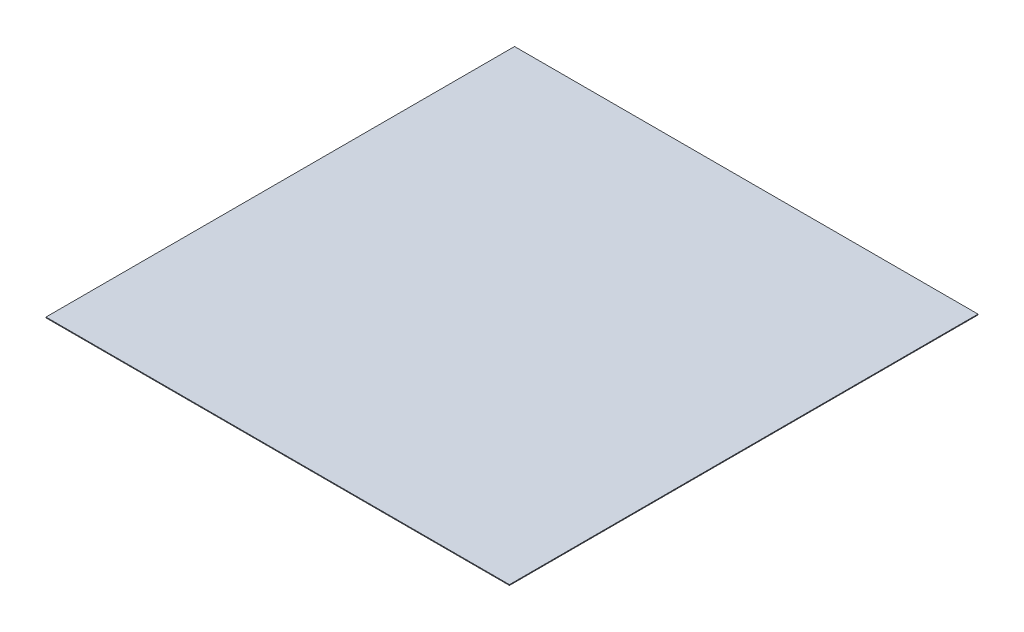
from build123d import *

# Parameters (mm, degrees)
SKETCH1_W           = 910
SKETCH1_H           = 920
BOSS_EXTRUDE1_DEPTH = 1.5


with BuildPart() as part:
    # Sketch1 → Boss-Extrude1 (new body)
    with BuildSketch(Plane(origin=(0, 0, 0), x_dir=(1, 0, 0), z_dir=(0, 1, 0))):
        Rectangle(SKETCH1_W, SKETCH1_H)
    extrude(amount=BOSS_EXTRUDE1_DEPTH)


solid = part.part
